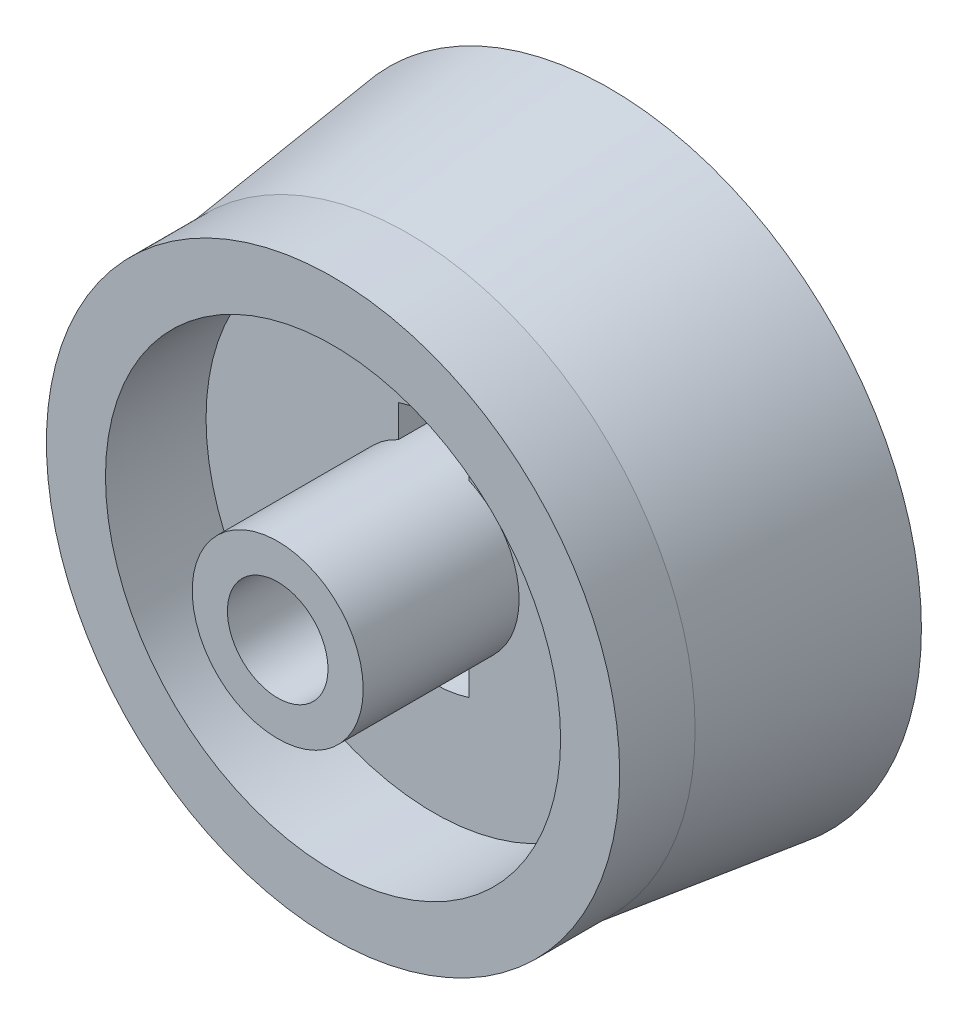
from build123d import *

# Parameters (mm, degrees)
SKETCH_1_R           = 1.7
SKETCH_1_R_2         = 1
EXTRUDE_1_DEPTH      = 1.1
EXTRUDE_1_DEPTH_BACK = 2
SKETCH_1_3_R         = 5.7
SKETCH_1_3_R_2       = 4.525
EXTRUDE_2_DEPTH      = 1.5
SKETCH_2_R           = 5
EXTRUDE_3_DEPTH      = 1.2
SKETCH_2_5_R         = 1
CUT_EXTRUDE_3_DEPTH  = 2.2
SKETCH_6_R           = 1.15
CUT_EXTRUDE_4_DEPTH  = 1.1
SKETCH_4_W           = 0.5
SKETCH_4_H           = 0.375
SKETCH_7_R           = 5.325
CUT_EXTRUDE_5_DEPTH  = 0.7


with BuildPart() as part:
    # Sketch 1 → Extrude 1 (new body, two sides)
    with BuildSketch(Plane.XY) as extrude_1_sk:
        Circle(SKETCH_1_R)
        Circle(SKETCH_1_R_2, mode=Mode.SUBTRACT)
    extrude(amount=EXTRUDE_1_DEPTH)
    extrude(extrude_1_sk.sketch, amount=-EXTRUDE_1_DEPTH_BACK)

    # Sketch 2 → Extrude 3 (add)
    with BuildSketch(Plane(origin=(0, 0, -2), x_dir=(-1, 0, 0), z_dir=(0, 0, -1))):
        Circle(SKETCH_2_R)
    extrude(amount=EXTRUDE_3_DEPTH)

    # Sketch 2_5 → Cut-Extrude 3 (cut, through all)
    with BuildSketch(Plane(origin=(0, 0, -2), x_dir=(-1, 0, 0), z_dir=(0, 0, -1))):
        with BuildLine():
            Line((-0.7, -1.549193338), (-0.7, -2.19089023))
            ThreePointArc((-0.7, -2.19089023), (0, -2.3), (0.7, -2.19089023))
            Line((0.7, -2.19089023), (0.7, -1.549193338))
            ThreePointArc((0.7, -1.549193338), (0, -1.7), (-0.7, -1.549193338))
        make_face()
        with BuildLine():
            ThreePointArc((0.7, 2.19089023), (0, 2.3), (-0.7, 2.19089023))
            Line((-0.7, 2.19089023), (-0.7, 1.549193338))
            ThreePointArc((-0.7, 1.549193338), (0, 1.7), (0.7, 1.549193338))
            Line((0.7, 1.549193338), (0.7, 2.19089023))
        make_face()
        with BuildLine():
            Line((-0.7, -1.549193338), (-0.7, -2.19089023))
            ThreePointArc((-0.7, -2.19089023), (0, -2.3), (0.7, -2.19089023))
            Line((0.7, -2.19089023), (0.7, -1.549193338))
            ThreePointArc((0.7, -1.549193338), (0, -1.7), (-0.7, -1.549193338))
        make_face()
        with BuildLine():
            ThreePointArc((0.7, 2.19089023), (0, 2.3), (-0.7, 2.19089023))
            Line((-0.7, 2.19089023), (-0.7, 1.549193338))
            ThreePointArc((-0.7, 1.549193338), (0, 1.7), (0.7, 1.549193338))
            Line((0.7, 1.549193338), (0.7, 2.19089023))
        make_face()
        with Locations(Location((0, 0, 0), (0, 0, 180))):  # turned: the seam where the file's is
            Circle(SKETCH_2_5_R)
    extrude(amount=CUT_EXTRUDE_3_DEPTH, mode=Mode.SUBTRACT)

    # Sketch 6 → Cut-Extrude 4 (cut)
    with BuildSketch(Plane(origin=(0, 0, -3.2), x_dir=(-1, 0, 0), z_dir=(0, 0, -1))):
        Circle(SKETCH_6_R)
    extrude(amount=-CUT_EXTRUDE_4_DEPTH, mode=Mode.SUBTRACT)



with BuildPart() as body_2:
    # Sketch 1_3 → Extrude 2 (new body)
    with BuildSketch(Plane.XY):
        Circle(SKETCH_1_3_R)
        Circle(SKETCH_1_3_R_2, mode=Mode.SUBTRACT)
    extrude(amount=-EXTRUDE_2_DEPTH)


with BuildPart() as part_1:
    add(part.part)

    add(body_2.part)  # Revolve 2 merges body 2
    # Sketch 4 → Revolve 2 (revolve)
    with BuildSketch(Plane(origin=(0, 0, 0), x_dir=(0, 0, -1), z_dir=(1, 0, 0)), mode=Mode.PRIVATE) as revolve_2_sk:
        Polygon((1.5, 5.7), (5.5, 6.2), (5.5, 4.9), (1.5, 4.9), align=None)
        with Locations((1.75, 4.7125)):
            Rectangle(SKETCH_4_W, SKETCH_4_H)
    revolve(revolve_2_sk.sketch.rotate(Axis((0, 0, 1000), (0, 0, -1)), 90), axis=Axis((0, 0, 1000), (0, 0, -1)))  # turned: the seam where the file's is

    # Sketch 7 → Cut-Extrude 5 (cut)
    with BuildSketch(Plane(origin=(0, 0, -5.5), x_dir=(-1, 0, 0), z_dir=(0, 0, -1))):
        Circle(SKETCH_7_R)
    extrude(amount=-CUT_EXTRUDE_5_DEPTH, mode=Mode.SUBTRACT)


solid = part_1.part
